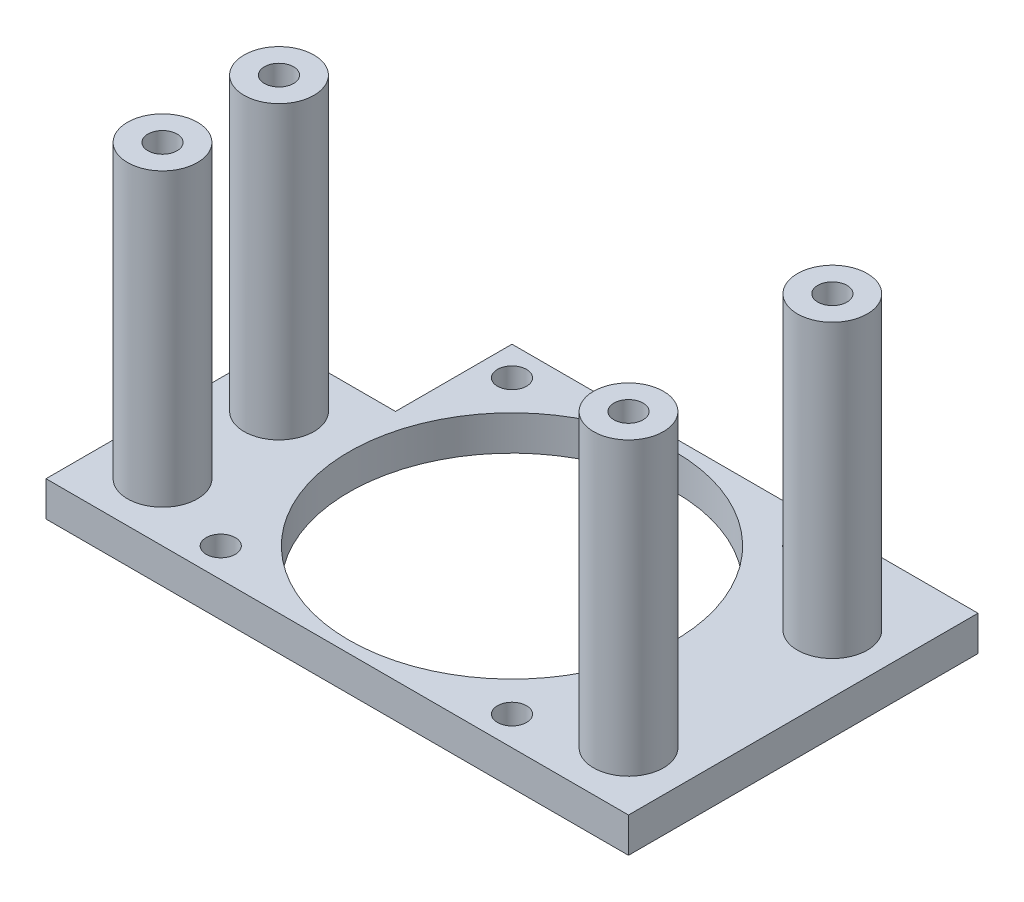
from build123d import *

# Parameters (mm, degrees)
SKETCH1_R           = 28
SKETCH1_R_2         = 2.5
BOSS_EXTRUDE1_DEPTH = 6
SKETCH2_R           = 6
BOSS_EXTRUDE2_DEPTH = 50
SKETCH3_R           = 2.5
CUT_EXTRUDE1_DEPTH  = 57
SKETCH5_R           = 4.25
CUT_EXTRUDE2_DEPTH  = 50


with BuildPart() as part:
    # Sketch1 → Boss-Extrude1 (new body)
    with BuildSketch(Plane(origin=(0, 0, 0), x_dir=(1, 0, 0), z_dir=(0, 1, 0))):
        Polygon((-50, -30), (50, -30), (50, 30), (-30, 30), (-30, 10), (-50, 10), align=None)
        Circle(SKETCH1_R, mode=Mode.SUBTRACT)
        with Locations((-25, 25)):
            Circle(SKETCH1_R_2, mode=Mode.SUBTRACT)
        with Locations((25, 25)):
            Circle(SKETCH1_R_2, mode=Mode.SUBTRACT)
        with Locations((25, -25)):
            Circle(SKETCH1_R_2, mode=Mode.SUBTRACT)
        with Locations((-25, -25)):
            Circle(SKETCH1_R_2, mode=Mode.SUBTRACT)
    extrude(amount=BOSS_EXTRUDE1_DEPTH)

    # Sketch2 → Boss-Extrude2 (add)
    with BuildSketch(Plane(origin=(0, 6, 0), x_dir=(1, 0, 0), z_dir=(0, 1, 0))):
        with Locations((-40, 0)):
            Circle(SKETCH2_R)
        with Locations((-40, -20)):
            Circle(SKETCH2_R)
        with Locations((40, 15)):
            Circle(SKETCH2_R)
        with Locations((40, -20)):
            Circle(SKETCH2_R)
    extrude(amount=BOSS_EXTRUDE2_DEPTH)

    # Sketch3 → Cut-Extrude1 (cut, through all)
    with BuildSketch(Plane(origin=(0, 56, 0), x_dir=(1, 0, 0), z_dir=(0, 1, 0))):
        with Locations((-40, 0)):
            Circle(SKETCH3_R)
        with Locations((-40, -20)):
            Circle(SKETCH3_R)
        with Locations((40, -20)):
            Circle(SKETCH3_R)
        with Locations((40, 15)):
            Circle(SKETCH3_R)
    extrude(amount=-CUT_EXTRUDE1_DEPTH, mode=Mode.SUBTRACT)

    # Sketch5 → Cut-Extrude2 (cut)
    with BuildSketch(Plane.XZ):
        with Locations((-40, 0)):
            Circle(SKETCH5_R)
        with Locations((-40, 20)):
            Circle(SKETCH5_R)
        with Locations((40, 20)):
            Circle(SKETCH5_R)
        with Locations((40, -15)):
            Circle(SKETCH5_R)
    extrude(amount=-CUT_EXTRUDE2_DEPTH, mode=Mode.SUBTRACT)


solid = part.part
